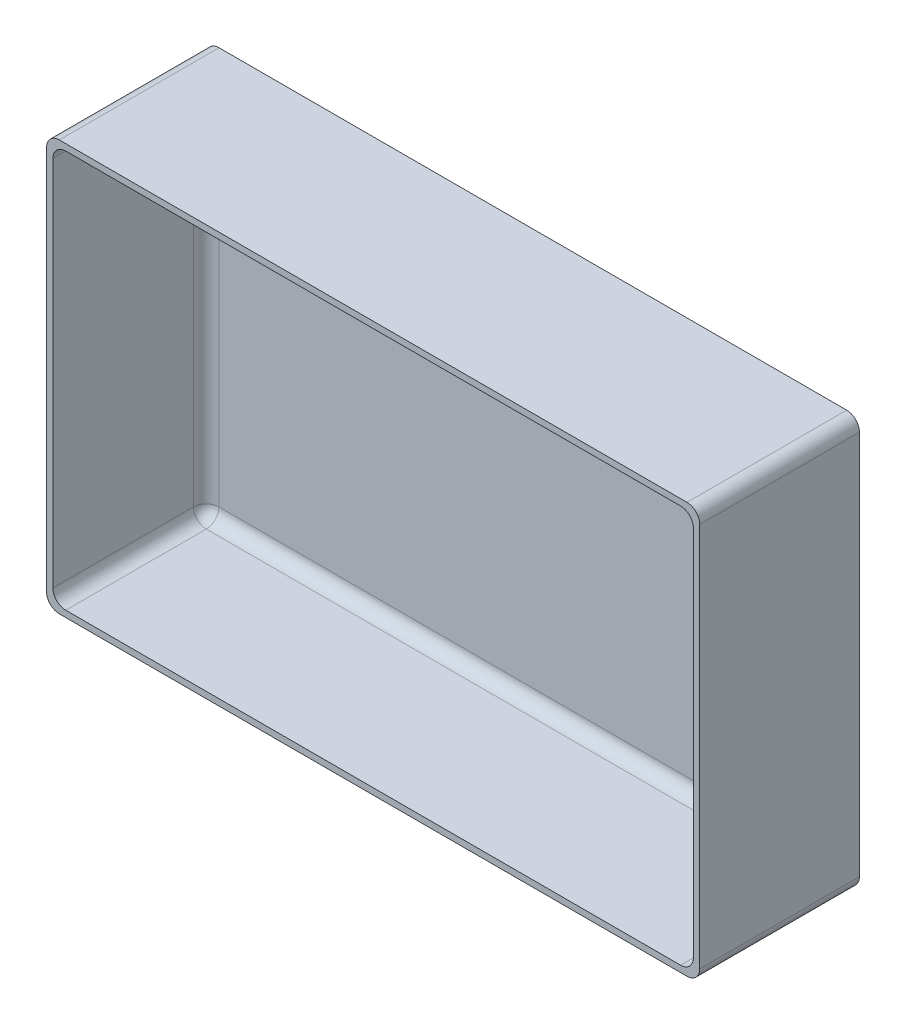
from build123d import *

# Parameters (mm, degrees)
ESQUISSE1_W        = 81.8
ESQUISSE1_H        = 51.4
BOSS_EXTRU_1_DEPTH = 20
COQUE1_T           = -0.8
CONG_1_R           = 1.6


with BuildPart() as part:
    # Esquisse1 → Boss.-Extru.1 (new body)
    with BuildSketch(Plane.XY):
        Rectangle(ESQUISSE1_W, ESQUISSE1_H)
    extrude(amount=BOSS_EXTRU_1_DEPTH)

    # Coque1
    coque1_openings = [part.faces().sort_by_distance(p)[0] for p in [
        (0, 0, 20),
    ]]
    offset(amount=COQUE1_T, openings=coque1_openings, kind=Kind.INTERSECTION)

    # Congé1
    cong_1_edges = [part.edges().sort_by_distance(p)[0] for p in [
        (40.1, 0, 0.8),
        (40.1, -24.9, 10.4),
        (0, 24.9, 0.8),
        (40.1, 24.9, 10.4),
        (-40.1, 0, 0.8),
        (-40.1, 24.9, 10.4),
        (0, -24.9, 0.8),
        (-40.1, -24.9, 10.4),
        (40.9, -25.7, 10),
        (-40.9, -25.7, 10),
        (-40.9, 25.7, 10),
        (40.9, 25.7, 10),
    ]]
    fillet(cong_1_edges, radius=CONG_1_R)


solid = part.part
